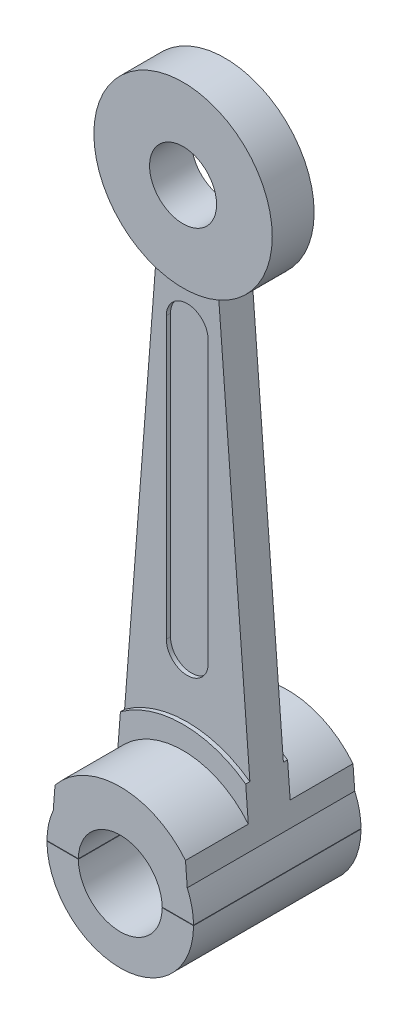
from build123d import *

# Parameters (mm, degrees)
SKETCH2_R                = 2.13
SKETCH2_R_2              = 0.8
BOSS_EXTRUDE1_DEPTH      = 0.5
SKETCH2_R_3              = 2.54
SKETCH2_R_4              = 1
BOSS_EXTRUDE1_2_DEPTH    = 0.5
BOSS_EXTRUDE2_DEPTH      = 0.4
BOSS_EXTRUDE3_DEPTH      = 0.3
BOSS_EXTRUDE5_DEPTH      = 1.5
BOSS_EXTRUDE5_DEPTH_BACK = 2.5
SKETCH3_R                = 2
SKETCH3_R_2              = 1
CUT_EXTRUDE1_DEPTH       = 30.75
SKETCH5_W                = 8.281122101
SKETCH5_H                = 0.01
CUT_EXTRUDE2_DEPTH       = 30.75


with BuildPart() as part:
    # Sketch2 → Boss-Extrude1 (new, symmetric)
    with BuildSketch(Plane.XY):
        with Locations((0, 13.69)):
            Circle(SKETCH2_R)
        with Locations((0, 13.69)):
            Circle(SKETCH2_R_2, mode=Mode.SUBTRACT)
    extrude(amount=BOSS_EXTRUDE1_DEPTH, both=True)



with BuildPart() as body_2:
    # Sketch2 → Boss-Extrude1 2 (new, symmetric)
    with BuildSketch(Plane.XY):
        Circle(SKETCH2_R_3)
        Circle(SKETCH2_R_4, mode=Mode.SUBTRACT)
    extrude(amount=BOSS_EXTRUDE1_2_DEPTH, both=True)


with BuildPart() as part_1:
    add(part.part)

    add(body_2.part)  # Boss-Extrude2 merges body 2
    # Sketch2_3 → Boss-Extrude2 (add, symmetric)
    with BuildSketch(Plane.XY):
        with BuildLine():
            ThreePointArc((0.75, 11.696410273), (0, 11.56), (-0.75, 11.696410273))
            Line((-0.75, 11.696410273), (-1.65, 1.931087776))
            ThreePointArc((-1.65, 1.931087776), (0, 2.54), (1.65, 1.931087776))
            Line((1.65, 1.931087776), (0.75, 11.696410273))
        make_face()
        with BuildLine():
            ThreePointArc((-0.5, 10.69), (0, 11.19), (0.5, 10.69))
            Line((0.5, 10.69), (0.5, 4))
            ThreePointArc((0.5, 4), (0, 3.5), (-0.5, 4))
            Line((-0.5, 4), (-0.5, 10.69))
        make_face(mode=Mode.SUBTRACT)
    extrude(amount=BOSS_EXTRUDE2_DEPTH, both=True)

    # Sketch2_4 → Boss-Extrude3 (add, symmetric)
    with BuildSketch(Plane.XY):
        with BuildLine():
            Line((0.5, 4), (0.5, 10.69))
            ThreePointArc((0.5, 10.69), (0, 11.19), (-0.5, 10.69))
            Line((-0.5, 10.69), (-0.5, 4))
            ThreePointArc((-0.5, 4), (0, 3.5), (0.5, 4))
        make_face()
    extrude(amount=BOSS_EXTRUDE3_DEPTH, both=True)

    # Sketch3 → Boss-Extrude5 (add, two sides: drawn at the far end of the back side and taken through both)
    with BuildSketch(Plane.XY.offset(0.5).offset(-BOSS_EXTRUDE5_DEPTH_BACK)):
        Circle(SKETCH3_R)
        Circle(SKETCH3_R_2, mode=Mode.SUBTRACT)
    extrude(amount=BOSS_EXTRUDE5_DEPTH + BOSS_EXTRUDE5_DEPTH_BACK)

    # Sketch4 → Cut-Extrude1 (cut, symmetric)
    with BuildSketch(Plane.XY):
        with BuildLine():
            Line((-0.75, 11.696410273), (-2.90290804, 1.955281287))
            ThreePointArc((-2.90290804, 1.955281287), (0, -3.5), (2.90290804, 1.955281287))
            Line((2.90290804, 1.955281287), (0.75, 11.696410273))
            Line((0.75, 11.696410273), (1.6, 0.708872344))
            ThreePointArc((1.6, 0.708872344), (0, -1.75), (-1.6, 0.708872344))
            Line((-1.6, 0.708872344), (-0.75, 11.696410273))
        make_face()
    extrude(amount=CUT_EXTRUDE1_DEPTH, both=True, mode=Mode.SUBTRACT)

    # Sketch5 → Cut-Extrude2 (cut, symmetric)
    with BuildSketch(Plane.XY):
        with Locations((-0.041360672, 0.005)):
            Rectangle(SKETCH5_W, SKETCH5_H)
    extrude(amount=CUT_EXTRUDE2_DEPTH, both=True, mode=Mode.SUBTRACT)


with BuildPart() as cut_extrude2_piece_1:
    # of the separate pieces the step leaves, piece 1, a body of its own (cut_extrude2_pieces)
    add(part_1.part.solids().sort_by_distance((1.496043311, 2.052670069, -0.5))[0])


with BuildPart() as cut_extrude2_piece_2:
    # of the separate pieces the step leaves, piece 2, a body of its own (cut_extrude2_pieces)
    add(part_1.part.solids().sort_by_distance((-1.75, 0, -2))[0])


solid = Compound([cut_extrude2_piece_1.part, cut_extrude2_piece_2.part])
